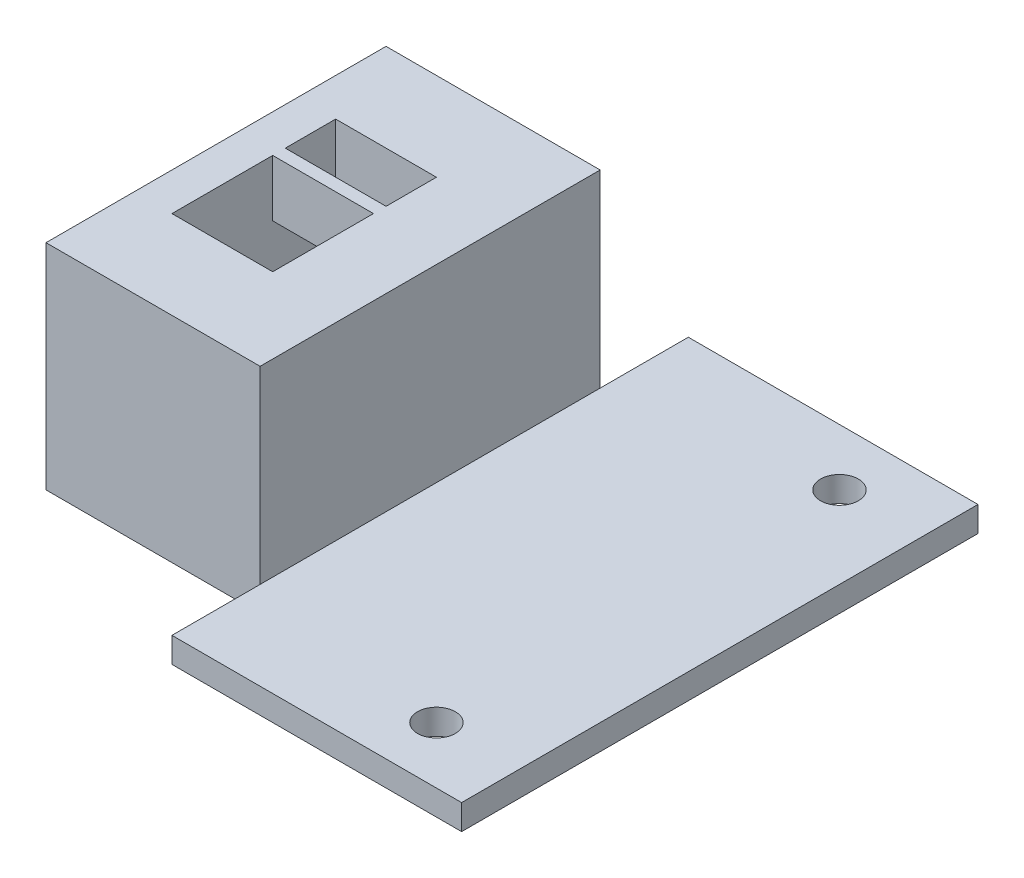
from build123d import *

# Parameters (mm, degrees)
SALIENTE_EXTRUIR1_DEPTH = 41
CROQUIS2_R              = 1.5
CORTAR_EXTRUIR1_DEPTH   = 2
CORTAR_EXTRUIR2_START   = -17
CROQUIS3_W              = 8
CROQUIS3_H              = 13
CROQUIS3_W_2            = 17
CROQUIS3_H_2            = 7
CORTAR_EXTRUIR2_DEPTH   = 17
CROQUIS4_W              = 8
CROQUIS4_H              = 1
SALIENTE_EXTRUIR2_DEPTH = 4.5


with BuildPart() as part:
    # Croquis1 → Saliente-Extruir1 (new body)
    with BuildSketch(Plane.XY):
        Polygon((-65.37305766, 23.186813187), (-48.37305766, 23.186813187), (-48.37305766, 8.186813187), (-25.37305766, 8.186813187), (-25.37305766, 6.186813187), (-65.37305766, 6.186813187), align=None)
    extrude(amount=SALIENTE_EXTRUIR1_DEPTH)

    # Croquis2 → Cortar-Extruir1 (cut)
    with BuildSketch(Plane.XZ.offset(-6.186813187)):
        with Locations((-31.87305766, 36.5)):
            Circle(CROQUIS2_R)
        with Locations((-31.87305766, 4.5)):
            Circle(CROQUIS2_R)
    extrude(amount=-CORTAR_EXTRUIR1_DEPTH, mode=Mode.SUBTRACT)

    # Croquis3 → Cortar-Extruir2 (cut)
    with BuildSketch(Plane.XZ.offset(-6.186813187).offset(CORTAR_EXTRUIR2_START)):
        with Locations((-58.37305766, 20.5)):
            Rectangle(CROQUIS3_W, CROQUIS3_H)
        with Locations((-56.87305766, 37.5)):
            Rectangle(CROQUIS3_W_2, CROQUIS3_H_2)
        with Locations((-56.87305766, 3.5)):
            Rectangle(CROQUIS3_W_2, CROQUIS3_H_2)
    extrude(amount=CORTAR_EXTRUIR2_DEPTH, mode=Mode.SUBTRACT)

    # Croquis4 → Saliente-Extruir2 (add)
    with BuildSketch(Plane(origin=(0, 23.186813187, 0), x_dir=(1, 0, 0), z_dir=(0, 1, 0))):
        with Locations((-58.37305766, -18.5)):
            Rectangle(CROQUIS4_W, CROQUIS4_H)
    extrude(amount=-SALIENTE_EXTRUIR2_DEPTH)


solid = part.part
